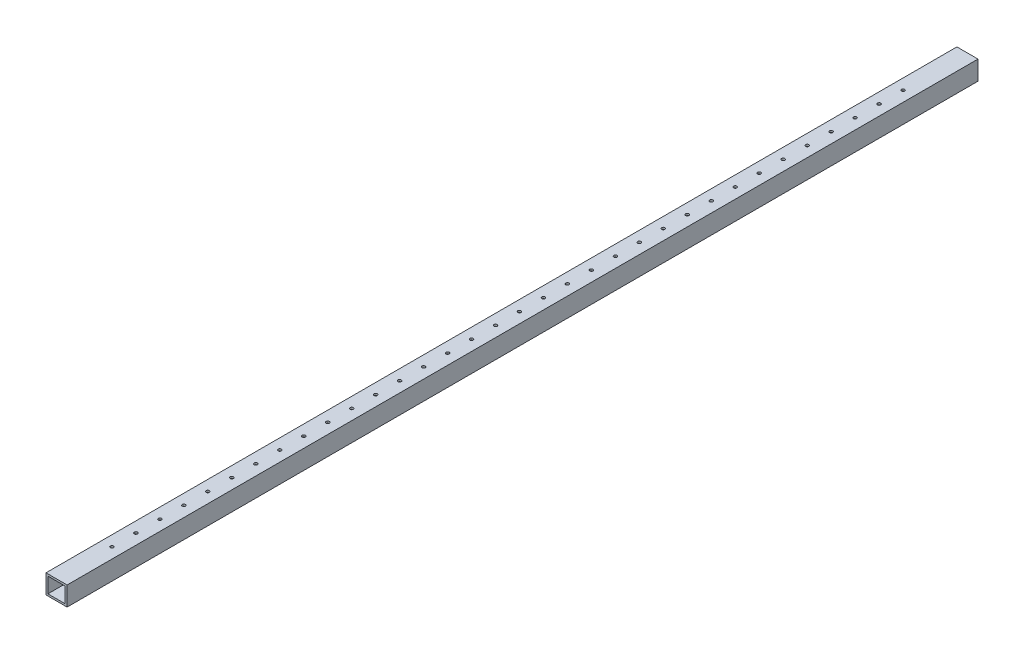
from build123d import *

# Parameters (mm, degrees)
SKETCH2_W           = 44
SKETCH2_H           = 40.022099447
SKETCH2_W_2         = 36
SKETCH2_H_2         = 32.022099447
EXTRUDE_THIN1_DEPTH = 950
SKETCH3_R           = 3.35
CUT_EXTRUDE1_DEPTH  = 41.022099448


with BuildPart() as part:
    # Sketch2 → Extrude-Thin1 (new body, symmetric)
    with BuildSketch(Plane.XY):
        with Locations((0.028084851, 0.02246788)):
            Rectangle(SKETCH2_W, SKETCH2_H)
        with Locations((0.028084851, 0.02246788)):
            Rectangle(SKETCH2_W_2, SKETCH2_H_2, mode=Mode.SUBTRACT)
    extrude(amount=EXTRUDE_THIN1_DEPTH, both=True)

    # Sketch3 → Cut-Extrude1 (cut, through all)
    with BuildSketch(Plane(origin=(0, 20.033517604, 0), x_dir=(1, 0, 0), z_dir=(0, 1, 0))):
        with Locations((0, 815.652483779)):
            Circle(SKETCH3_R)
        with Locations((0, 765.652483779)):
            Circle(SKETCH3_R)
        with Locations((0, 715.652483779)):
            Circle(SKETCH3_R)
        with Locations((0, 665.652483779)):
            Circle(SKETCH3_R)
        with Locations((0, 615.652483779)):
            Circle(SKETCH3_R)
        with Locations((0, 565.652483779)):
            Circle(SKETCH3_R)
        with Locations((0, 515.652483779)):
            Circle(SKETCH3_R)
        with Locations((0, 465.652483779)):
            Circle(SKETCH3_R)
        with Locations((0, 415.652483779)):
            Circle(SKETCH3_R)
        with Locations((0, 365.652483779)):
            Circle(SKETCH3_R)
        with Locations((0, 315.652483779)):
            Circle(SKETCH3_R)
        with Locations((0, 265.652483779)):
            Circle(SKETCH3_R)
        with Locations((0, 215.652483779)):
            Circle(SKETCH3_R)
        with Locations((0, 165.652483779)):
            Circle(SKETCH3_R)
        with Locations((0, 115.652483779)):
            Circle(SKETCH3_R)
        with Locations((0, 65.652483779)):
            Circle(SKETCH3_R)
        with Locations((0, 15.652483779)):
            Circle(SKETCH3_R)
        with Locations((0, -34.347516221)):
            Circle(SKETCH3_R)
        with Locations((0, -84.347516221)):
            Circle(SKETCH3_R)
        with Locations((0, -134.347516221)):
            Circle(SKETCH3_R)
        with Locations((0, -184.347516221)):
            Circle(SKETCH3_R)
        with Locations((0, -234.347516221)):
            Circle(SKETCH3_R)
        with Locations((0, -284.347516221)):
            Circle(SKETCH3_R)
        with Locations((0, -334.347516221)):
            Circle(SKETCH3_R)
        with Locations((0, -384.347516221)):
            Circle(SKETCH3_R)
        with Locations((0, -434.347516221)):
            Circle(SKETCH3_R)
        with Locations((0, -484.347516221)):
            Circle(SKETCH3_R)
        with Locations((0, -534.347516221)):
            Circle(SKETCH3_R)
        with Locations((0, -584.347516221)):
            Circle(SKETCH3_R)
        with Locations((0, -634.347516221)):
            Circle(SKETCH3_R)
        with Locations((0, -684.347516221)):
            Circle(SKETCH3_R)
        with Locations((0, -734.347516221)):
            Circle(SKETCH3_R)
        with Locations((0, -784.347516221)):
            Circle(SKETCH3_R)
        with Locations((0, -834.347516221)):
            Circle(SKETCH3_R)
    extrude(amount=-CUT_EXTRUDE1_DEPTH, mode=Mode.SUBTRACT)


solid = part.part
